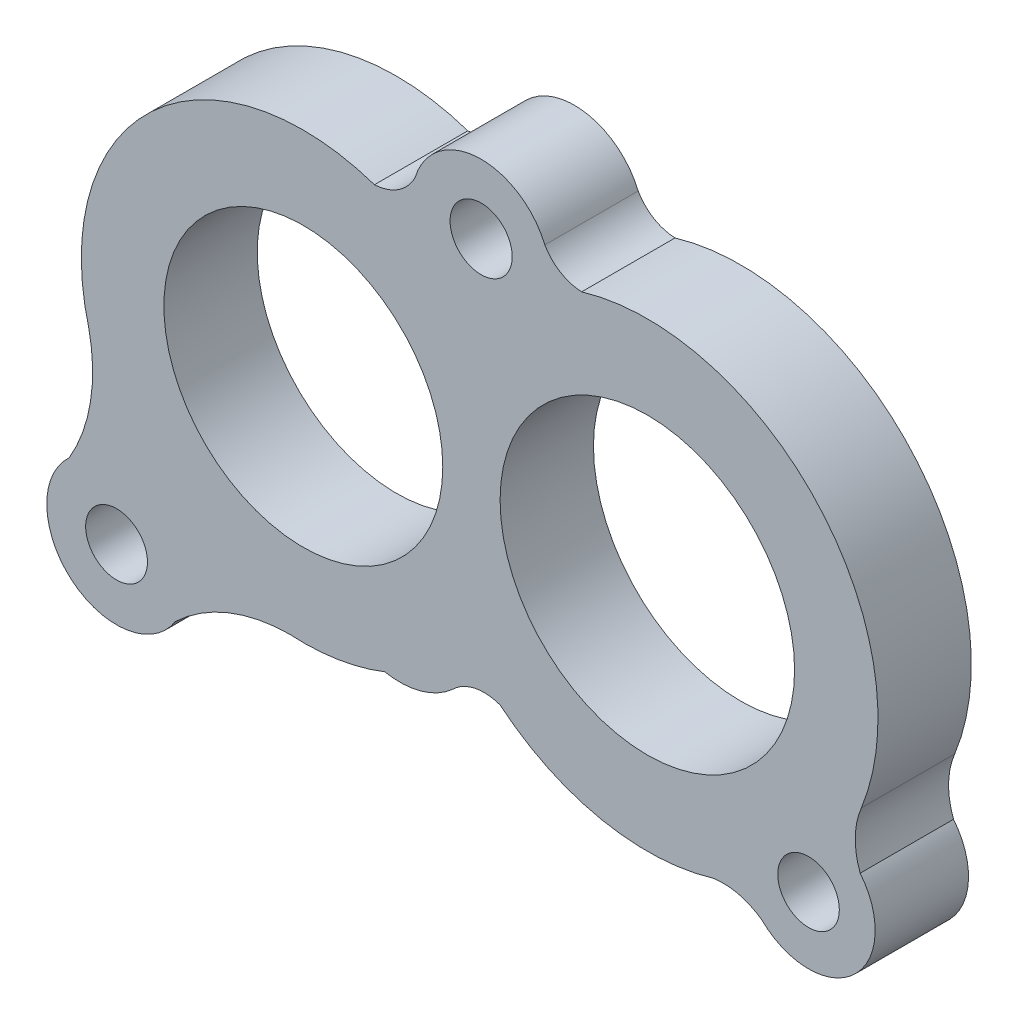
from build123d import *

# Parameters (mm, degrees)
SKETCH2_R           = 3.310722334
SKETCH2_R_2         = 3.296718814
SKETCH2_R_3         = 14.939183171
SKETCH2_R_4         = 15.775070875
SKETCH2_R_5         = 3.328969896
BOSS_EXTRUDE1_DEPTH = 10


with BuildPart() as part:
    # Sketch2 → Boss-Extrude1 (new body)
    with BuildSketch(Plane.XY):
        with BuildLine():
            ThreePointArc((1167.675319769, 692.531209966), (1170.060778441, 693.818219259), (1172.763939692, 693.618907326))
            ThreePointArc((1172.763939692, 693.618907326), (1183.613308441, 688.423787767), (1195.630078304, 688.967213524))
            ThreePointArc((1195.630078304, 688.967213524), (1198.351418182, 688.838111227), (1200.819062261, 687.683515696))
            ThreePointArc((1200.819062261, 687.683515696), (1210.625036277, 687.522306041), (1211.340535268, 697.303470396))
            ThreePointArc((1211.340535268, 697.303470396), (1210.809475012, 700.246380188), (1211.368402544, 703.184124739))
            ThreePointArc((1211.368402544, 703.184124739), (1211.41694342, 703.305912697), (1211.4674242, 703.42690945))
            ThreePointArc((1211.4674242, 703.42690945), (1206.80719309, 729.274429889), (1181.506693094, 736.324023269))
            ThreePointArc((1181.506693094, 736.324023269), (1179.223280206, 736.998421734), (1177.558977414, 738.701032648))
            ThreePointArc((1177.558977414, 738.701032648), (1170.340733714, 743.238904055), (1163.643592882, 737.962198293))
            ThreePointArc((1163.643592882, 737.962198293), (1161.850792017, 735.976541745), (1159.303859855, 735.157943289))
            ThreePointArc((1159.303859855, 735.157943289), (1135.421637358, 730.00830056), (1128.710038296, 706.517157342))
            ThreePointArc((1128.710038296, 706.517157342), (1128.880818562, 699.796244734), (1126.59806647, 693.472568978))
            ThreePointArc((1126.59806647, 693.472568978), (1126.887875726, 682.243065003), (1137.986275865, 683.978364196))
            ThreePointArc((1137.986275865, 683.978364196), (1143.619411431, 687.605871257), (1150.191627268, 688.908561852))
            ThreePointArc((1150.191627268, 688.908561852), (1155.387088921, 689.151648756), (1160.40529024, 690.518970431))
            ThreePointArc((1160.40529024, 690.518970431), (1164.277487038, 690.668174132), (1167.675319769, 692.531209966))
        make_face()
        with Locations((1131.674937322, 687.985100392)):
            Circle(SKETCH2_R, mode=Mode.SUBTRACT)
        with Locations((1205.807348969, 692.791475029)):
            Circle(SKETCH2_R_2, mode=Mode.SUBTRACT)
        with Locations((1151.684129253, 712.636857749)):
            Circle(SKETCH2_R_3, mode=Mode.SUBTRACT)
        with Locations((1188.539010567, 712.636857749)):
            Circle(SKETCH2_R_4, mode=Mode.SUBTRACT)
        with Locations((1170.732894481, 735.852853522)):
            Circle(SKETCH2_R_5, mode=Mode.SUBTRACT)
    extrude(amount=BOSS_EXTRUDE1_DEPTH)


solid = part.part
